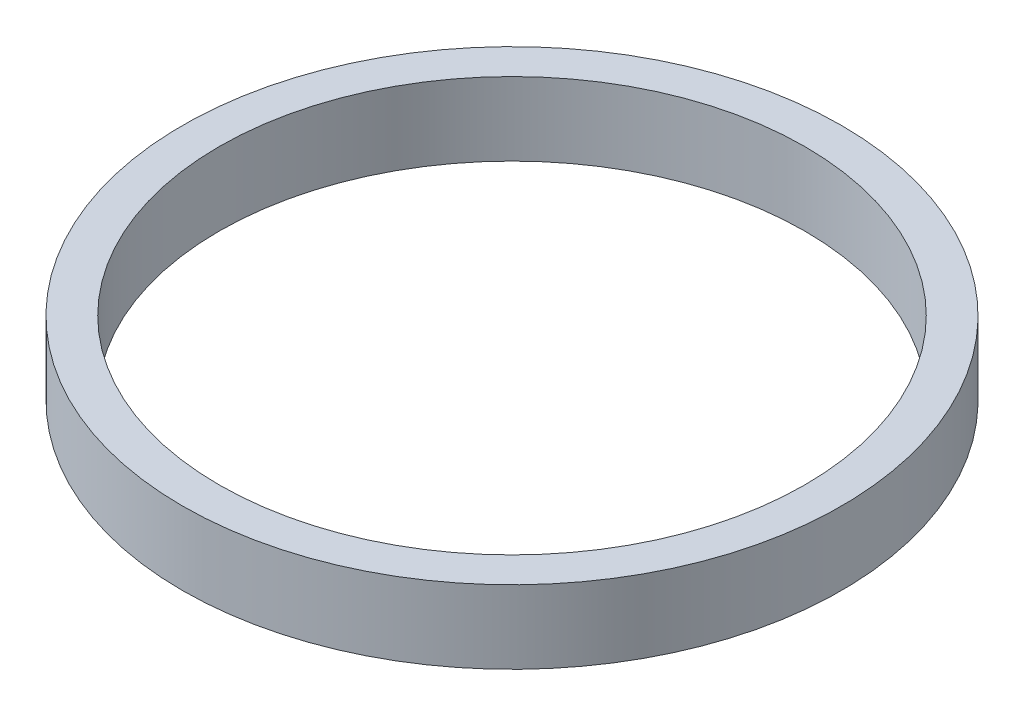
from build123d import *

# Parameters (mm, degrees)
SKETCH1_R           = 45
BOSS_EXTRUDE1_DEPTH = 10
SKETCH2_R           = 40
CUT_EXTRUDE1_DEPTH  = 10


with BuildPart() as part:
    # Sketch1 → Boss-Extrude1 (new body)
    with BuildSketch(Plane(origin=(0, 0, 0), x_dir=(1, 0, 0), z_dir=(0, 1, 0))):
        Circle(SKETCH1_R)
    extrude(amount=BOSS_EXTRUDE1_DEPTH)

    # Sketch2 → Cut-Extrude1 (cut)
    with BuildSketch(Plane(origin=(0, 10, 0), x_dir=(1, 0, 0), z_dir=(0, 1, 0))):
        Circle(SKETCH2_R)
    extrude(amount=-CUT_EXTRUDE1_DEPTH, mode=Mode.SUBTRACT)


solid = part.part
